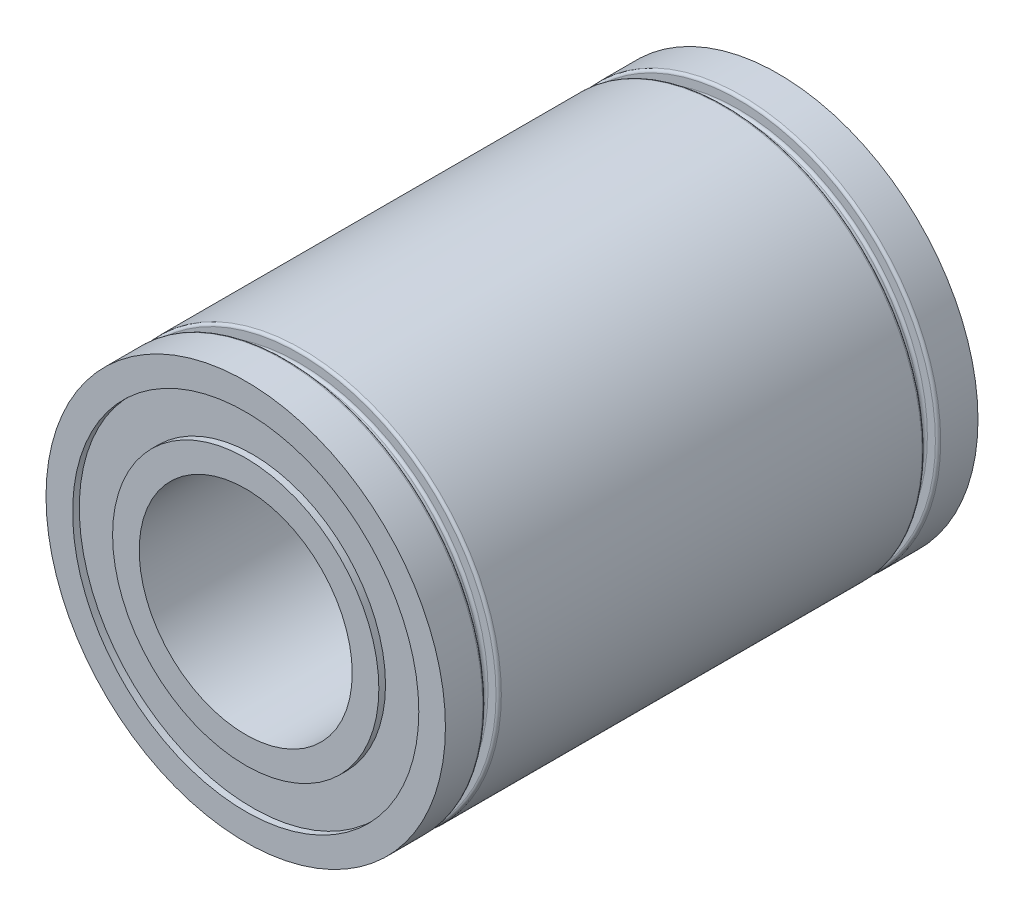
from build123d import *

# Parameters (mm, degrees)
SKETCH2_R             = 7.5
SKETCH2_R_2           = 6.5
BOSS_EXTRUDE1_DEPTH   = 10
SKETCH2_R_3           = 5
SKETCH2_R_4           = 4
BOSS_EXTRUDE1_2_DEPTH = 10
SKETCH2_3_R           = 6.5
SKETCH2_3_R_2         = 5
BOSS_EXTRUDE2_DEPTH   = 9.75
SKETCH3_W             = 1
SKETCH3_H             = 0.5
FILLET1_R             = 0.1


with BuildPart() as part:
    # Sketch2 → Boss-Extrude1 (new, symmetric)
    with BuildSketch(Plane.XY):
        Circle(SKETCH2_R)
        Circle(SKETCH2_R_2, mode=Mode.SUBTRACT)
    extrude(amount=BOSS_EXTRUDE1_DEPTH, both=True)



with BuildPart() as body_2:
    # Sketch2 → Boss-Extrude1 2 (new, symmetric)
    with BuildSketch(Plane.XY):
        Circle(SKETCH2_R_3)
        Circle(SKETCH2_R_4, mode=Mode.SUBTRACT)
    extrude(amount=BOSS_EXTRUDE1_2_DEPTH, both=True)


with BuildPart() as part_1:
    add(part.part)

    add(body_2.part)  # Boss-Extrude2 merges body 2
    # Sketch2_3 → Boss-Extrude2 (add, symmetric)
    with BuildSketch(Plane.XY):
        Circle(SKETCH2_3_R)
        Circle(SKETCH2_3_R_2, mode=Mode.SUBTRACT)
    extrude(amount=BOSS_EXTRUDE2_DEPTH, both=True)

    # Sketch3 → Cut-Revolve1 (revolve, cut)
    with BuildSketch(Plane(origin=(0, 0, 0), x_dir=(1, 0, 0), z_dir=(0, 1, 0))):
        with Locations((7.5, 8.25)):
            Rectangle(SKETCH3_W, SKETCH3_H)
        with Locations((7.5, -8.25)):
            Rectangle(SKETCH3_W, SKETCH3_H)
    revolve(axis=Axis((0, 0, -10), (0, 0, 1)), mode=Mode.SUBTRACT)

    # Fillet1
    fillet1_edges = [part_1.edges().sort_by_distance(p)[0] for p in [
        (-7, 0, -8.5),
        (-7.5, 0, -8.5),
        (-7, 0, -8),
        (-7.5, 0, -8),
        (-7, 0, 8.5),
        (-7, 0, 8),
        (-7.5, 0, 8),
        (-7.5, 0, 8.5),
    ]]
    fillet(fillet1_edges, radius=FILLET1_R)


solid = part_1.part
